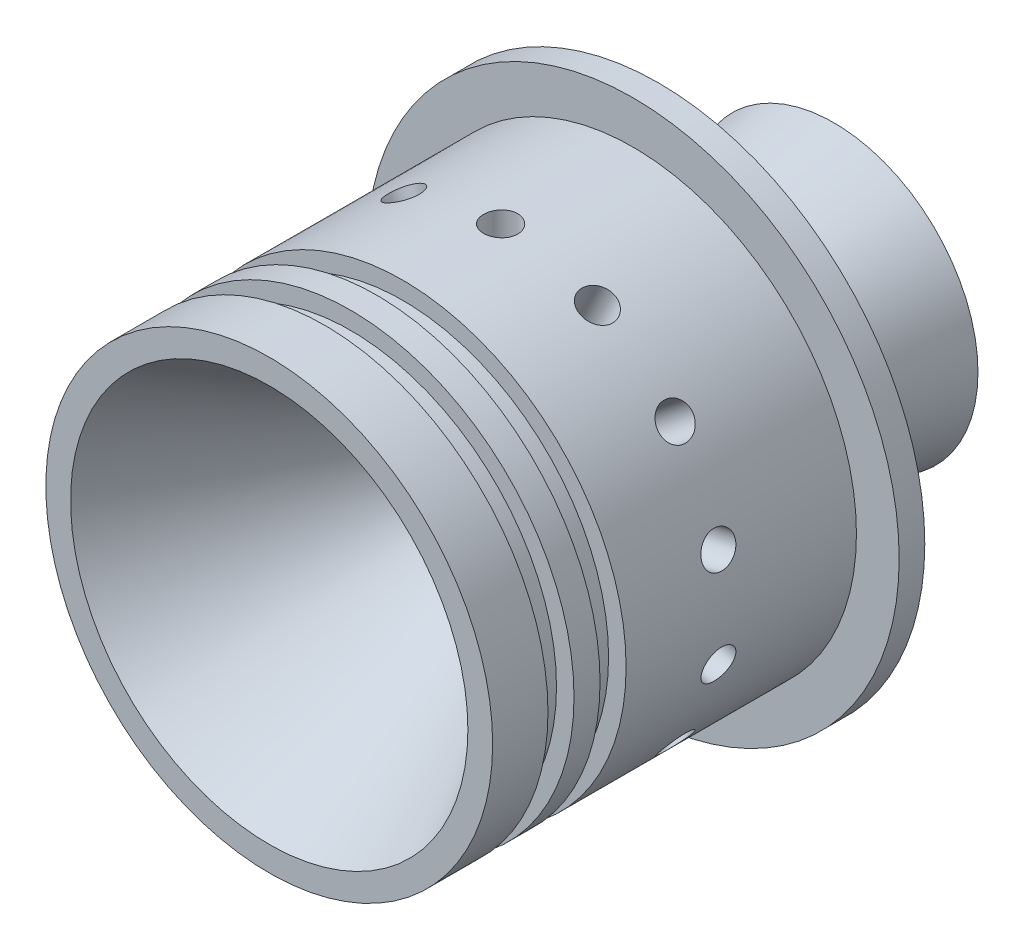
from build123d import *

# Parameters (mm, degrees)
MATRIZC1_COUNT = 14


with BuildPart() as part:
    # Croquis2 → Revolución1 (revolve)
    with BuildSketch(Plane(origin=(0, 0, 0), x_dir=(0, 0, -1), z_dir=(1, 0, 0))):
        with BuildLine():
            Line((0, 23.2509), (28.348346363, 6.883974596))
            ThreePointArc((28.348346363, 6.883974596), (28.589527318, 6.784074174), (28.848346363, 6.75))
            Line((28.848346363, 6.75), (30.3701887, 6.75))
            ThreePointArc((30.3701887, 6.75), (30.579245627, 6.760956209), (30.786012082, 6.793704799))
            Line((30.786012082, 6.793704799), (66.100354497, 14.3))
            Line((66.100354497, 14.3), (66.100354497, 16.855851487))
            Line((66.100354497, 16.855851487), (45.580397171, 12.494199912))
            Line((45.580397171, 12.494199912), (45.580397171, 26.0993))
            Line((45.580397171, 26.0993), (45.580397171, 31.1493))
            Line((45.580397171, 31.1493), (42.580397171, 31.1493))
            Line((42.580397171, 31.1493), (42.580397171, 26.1493))
            Line((42.580397171, 26.1493), (15.62, 26.1493))
            Line((15.62, 26.1493), (15.62, 24.0993))
            Line((15.62, 24.0993), (12.572, 24.0993))
            Line((12.572, 24.0993), (12.572, 26.1493))
            Line((12.572, 26.1493), (9.524, 26.1493))
            Line((9.524, 26.1493), (9.524, 24.0993))
            Line((9.524, 24.0993), (6.476, 24.0993))
            Line((6.476, 24.0993), (6.476, 26.1493))
            Line((6.476, 26.1493), (0, 26.1493))
            Line((0, 26.1493), (0, 23.2509))
        make_face()
    revolve(axis=Axis((0, 0, 14.017218159), (0, 0, -1)))

    # Croquis5 → Ø4.0mm Dowel Hole1 (revolve, cut)
    with BuildSketch(Plane(origin=(0, 26.1493, -27.080397171), x_dir=(0, 0, 1), z_dir=(1, 0, 0))):
        Polygon((0, 0), (0, 8.201721238), (2, 7), (2, 0), align=None)
    f_4_0mm_dowel_hole1 = revolve(axis=Axis((0, 32.4993, -27.080397171), (0, -1, 0)), mode=Mode.SUBTRACT)

    # MatrizC1: Ø4.0mm Dowel Hole1 ×14 about axis
    matrizc1_axis = Axis((0, 0, -15.62), (0, 0, 1))
    for i in range(1, MATRIZC1_COUNT):
        add(f_4_0mm_dowel_hole1.rotate(matrizc1_axis, i * 360 / MATRIZC1_COUNT), mode=Mode.SUBTRACT)


solid = part.part
